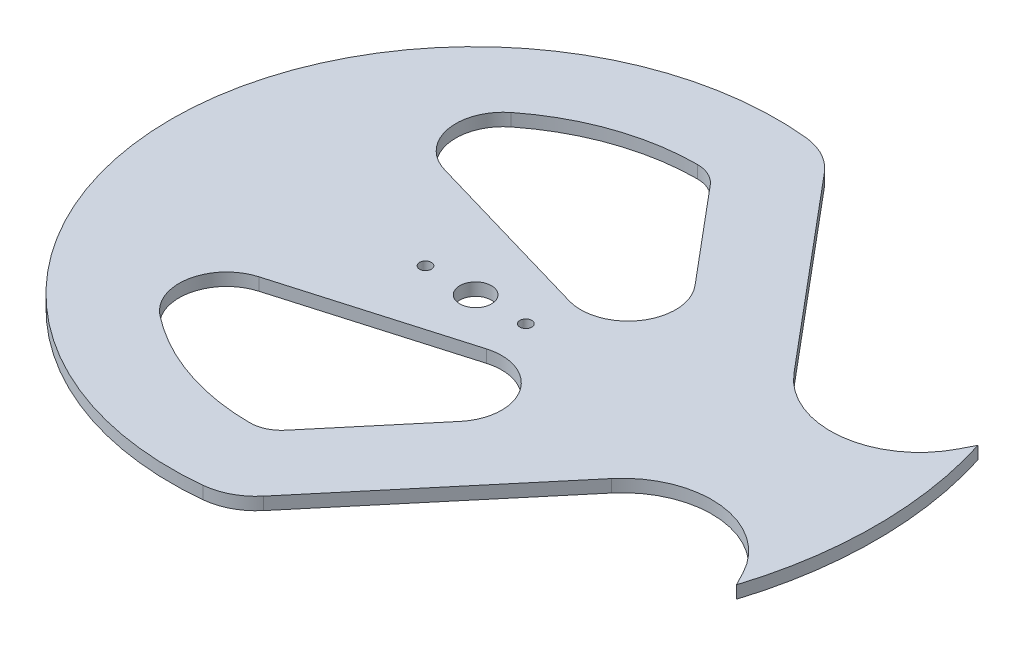
from build123d import *

# Parameters (mm, degrees)
BOSS_EXTRUDE1_DEPTH = 3.175
SKETCH2_R           = 4
CUT_EXTRUDE3_DEPTH  = 4.175
SKETCH3_R           = 1.5
CUT_EXTRUDE4_DEPTH  = 4.175


with BuildPart() as part:
    # Sketch1 → Boss-Extrude1 (new body)
    with BuildSketch(Plane(origin=(0, 0, 0), x_dir=(1, 0, 0), z_dir=(0, 1, 0))):
        with BuildLine():
            Line((96.897642196, 30.55170923), (95.120945792, 27.138707192))
            ThreePointArc((95.120945792, 27.138707192), (77.57215373, 15.134042144), (57.841053042, 23.055894918))
            Line((57.841053042, 23.055894918), (17.668897816, 70.931205231))
            ThreePointArc((17.668897816, 70.931205231), (13.19211244, 74.548556577), (7.682670578, 76.213755798))
            ThreePointArc((7.682670578, 76.213755798), (-76.6, 0), (7.682670578, -76.213755798))
            ThreePointArc((7.682670578, -76.213755798), (13.19211244, -74.548556577), (17.668897816, -70.931205231))
            Line((17.668897816, -70.931205231), (57.841053042, -23.055894918))
            ThreePointArc((57.841053042, -23.055894918), (77.57215373, -15.134042144), (95.120945792, -27.138707192))
            Line((95.120945792, -27.138707192), (96.897642196, -30.55170923))
            ThreePointArc((96.897642196, -30.55170923), (101.6, 0), (96.897642196, 30.55170923))
        make_face()
        with BuildLine():
            Line((5.98413489, 53.742086889), (26.146554137, 29.713451316))
            ThreePointArc((26.146554137, 29.713451316), (27.003715662, 15.442284424), (13.595828747, 10.479472842))
            Line((13.595828747, 10.479472842), (-31.001636142, 23.479472842))
            ThreePointArc((-31.001636142, 23.479472842), (-39.421951774, 32.705058554), (-35.081142025, 44.417040359))
            ThreePointArc((-35.081142025, 44.417040359), (-18.647504357, 53.439971756), (-0.16796068, 56.599750788))
            ThreePointArc((-0.16796068, 56.599750788), (3.225963821, 55.855256817), (5.98413489, 53.742086889))
        make_face(mode=Mode.SUBTRACT)
        with BuildLine():
            Line((5.98413489, -53.742086889), (26.146554137, -29.713451316))
            ThreePointArc((26.146554137, -29.713451316), (27.003715662, -15.442284424), (13.595828747, -10.479472842))
            Line((13.595828747, -10.479472842), (-31.001636142, -23.479472842))
            ThreePointArc((-31.001636142, -23.479472842), (-39.421951774, -32.705058554), (-35.081142025, -44.417040359))
            ThreePointArc((-35.081142025, -44.417040359), (-18.647504357, -53.439971756), (-0.16796068, -56.599750788))
            ThreePointArc((-0.16796068, -56.599750788), (3.225963821, -55.855256817), (5.98413489, -53.742086889))
        make_face(mode=Mode.SUBTRACT)
    extrude(amount=BOSS_EXTRUDE1_DEPTH)

    # Sketch2 → Cut-Extrude3 (cut, through all)
    with BuildSketch(Plane(origin=(0, 0, 0), x_dir=(1, 0, 0), z_dir=(0, 1, 0))):
        with Locations((0.378636362, 0)):
            Circle(SKETCH2_R)
    extrude(amount=CUT_EXTRUDE3_DEPTH, mode=Mode.SUBTRACT)

    # Sketch3 → Cut-Extrude4 (cut, through all)
    with BuildSketch(Plane(origin=(0, 0, 0), x_dir=(1, 0, 0), z_dir=(0, 1, 0))):
        with Locations((-12.321363638, 0)):
            Circle(SKETCH3_R)
        with Locations((13.078636362, 0)):
            Circle(SKETCH3_R)
    extrude(amount=CUT_EXTRUDE4_DEPTH, mode=Mode.SUBTRACT)


solid = part.part
